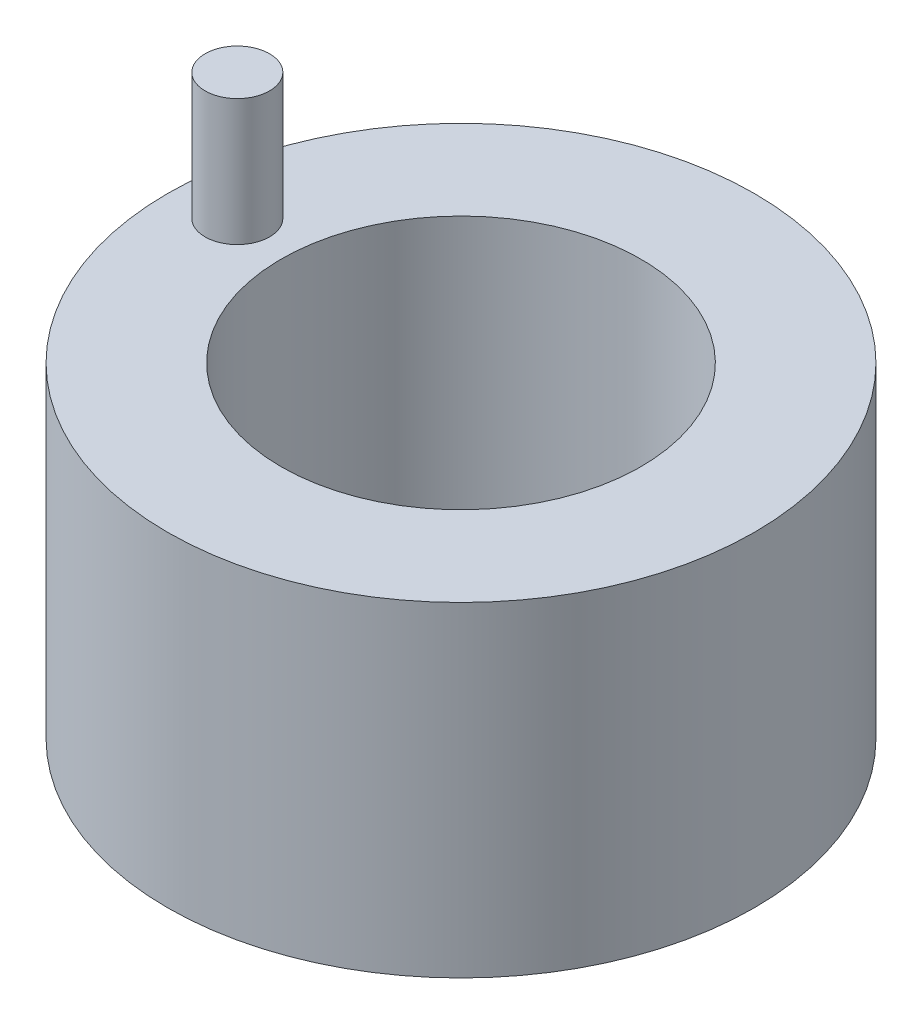
from build123d import *

# Parameters (mm, degrees)
SKETCH1_R           = 64.964891119
BOSS_EXTRUDE1_DEPTH = 72
SKETCH2_R           = 39.826869817
CUT_EXTRUDE1_DEPTH  = 72
SKETCH3_R           = 7.132695563
BOSS_EXTRUDE2_DEPTH = 28


with BuildPart() as part:
    # Sketch1 → Boss-Extrude1 (new body)
    with BuildSketch(Plane(origin=(0, 0, 0), x_dir=(1, 0, 0), z_dir=(0, 1, 0))):
        Circle(SKETCH1_R)
    extrude(amount=BOSS_EXTRUDE1_DEPTH)

    # Sketch2 → Cut-Extrude1 (cut)
    with BuildSketch(Plane(origin=(0, 72, 0), x_dir=(1, 0, 0), z_dir=(0, 1, 0))):
        Circle(SKETCH2_R)
    extrude(amount=-CUT_EXTRUDE1_DEPTH, mode=Mode.SUBTRACT)

    # Sketch3 → Boss-Extrude2 (add)
    with BuildSketch(Plane(origin=(0, 72, 0), x_dir=(1, 0, 0), z_dir=(0, 1, 0))):
        with Locations((-52.478167306, 2.956579855)):
            Circle(SKETCH3_R)
    extrude(amount=BOSS_EXTRUDE2_DEPTH)


solid = part.part
